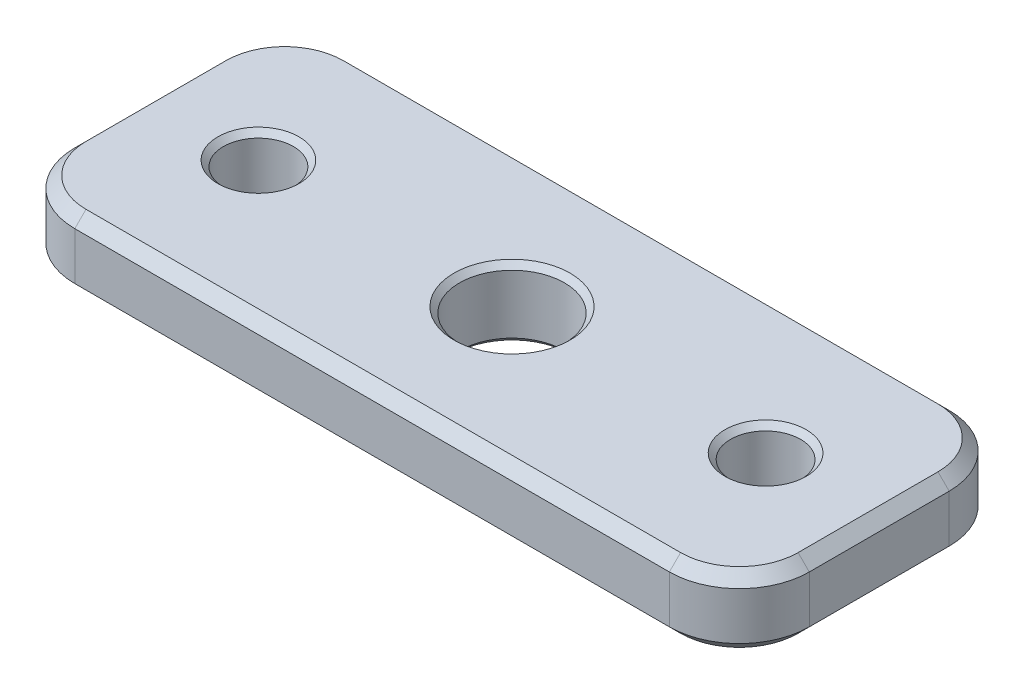
from build123d import *

# Parameters (mm, degrees)
SKETCH1_W           = 33.3375
SKETCH1_H           = 12.7
SKETCH1_R           = 1.5875
SKETCH1_R_2         = 2.38125
BOSS_EXTRUDE1_DEPTH = 3.175
FILLET1_R           = 3.175
CHAMFER2_SIZE       = 0.508
CHAMFER1_SIZE       = 0.254


with BuildPart() as part:
    # Sketch1 → Boss-Extrude1 (new body)
    with BuildSketch(Plane(origin=(0, 0, 0), x_dir=(1, 0, 0), z_dir=(0, 1, 0))):
        Rectangle(SKETCH1_W, SKETCH1_H)
        with Locations((-11.509375, 0)):
            Circle(SKETCH1_R, mode=Mode.SUBTRACT)
        with Locations((11.509375, 0)):
            Circle(SKETCH1_R, mode=Mode.SUBTRACT)
        Circle(SKETCH1_R_2, mode=Mode.SUBTRACT)
    extrude(amount=BOSS_EXTRUDE1_DEPTH)

    # Fillet1
    fillet1_edges = [part.edges().sort_by_distance(p)[0] for p in [
        (16.66875, 1.5875, 6.35),
        (-16.66875, 1.5875, 6.35),
        (-16.66875, 1.5875, -6.35),
        (16.66875, 1.5875, -6.35),
    ]]
    fillet(fillet1_edges, radius=FILLET1_R)

    # Chamfer2
    chamfer2_edges = [part.edges().sort_by_distance(p)[0] for p in [
        (16.66875, 0, 0),
        (16.66875, 3.175, 0),
        (0, 0, 6.35),
        (-16.66875, 0, 0),
        (0, 0, -6.35),
        (-15.73881403, 0, 5.42006403),
        (15.73881403, 0, -5.42006403),
        (-15.73881403, 0, -5.42006403),
        (15.73881403, 0, 5.42006403),
        (0, 3.175, 6.35),
        (0, 3.175, -6.35),
        (-16.66875, 3.175, 0),
        (-15.73881403, 3.175, 5.42006403),
        (15.73881403, 3.175, -5.42006403),
        (-15.73881403, 3.175, -5.42006403),
        (15.73881403, 3.175, 5.42006403),
    ]]
    chamfer(chamfer2_edges, length=CHAMFER2_SIZE)

    # Chamfer1
    chamfer1_edges = [part.edges().sort_by_distance(p)[0] for p in [
        (-13.096875, 0, 0),
        (-13.096875, 3.175, 0),
        (9.921875, 0, 0),
        (9.921875, 3.175, 0),
        (-2.38125, 0, 0),
        (-2.38125, 3.175, 0),
    ]]
    chamfer(chamfer1_edges, length=CHAMFER1_SIZE)


solid = part.part
